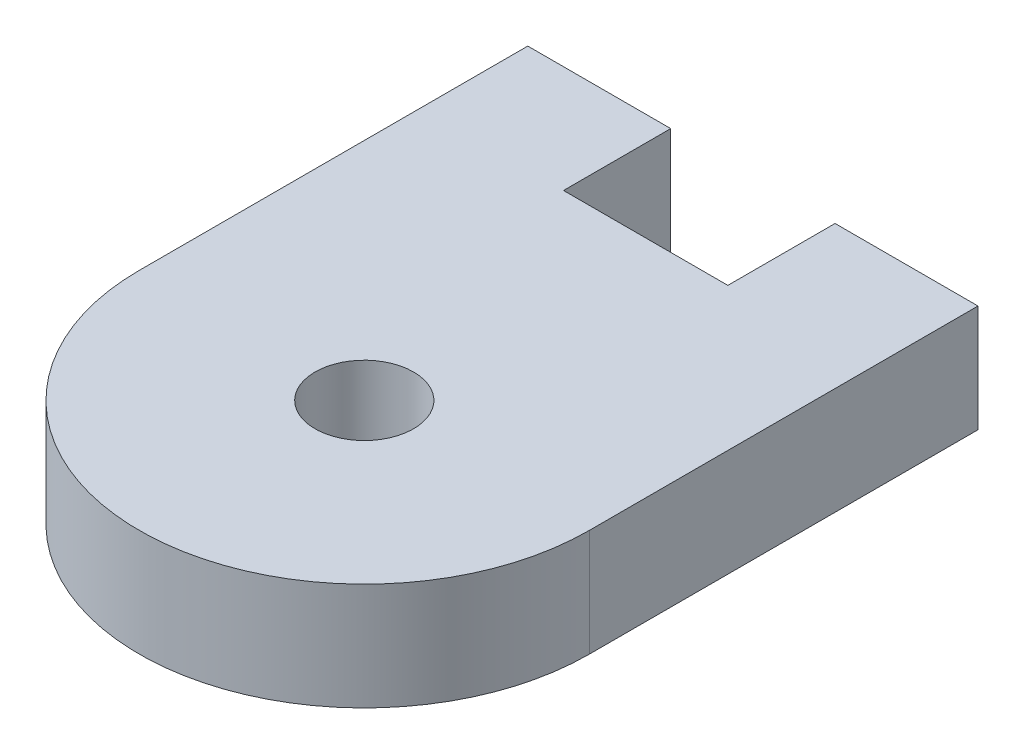
from build123d import *

# Parameters (mm, degrees)
BOSS_EXTRUDE1_DEPTH = 7.62
SKETCH2_R           = 3.5
CUT_EXTRUDE1_DEPTH  = 8.62
SKETCH3_W           = 10.16
SKETCH3_H           = 7.62
BOSS_EXTRUDE2_DEPTH = 7.62


with BuildPart() as part:
    # Sketch1 → Boss-Extrude1 (new body)
    with BuildSketch(Plane(origin=(0, 0, 0), x_dir=(1, 0, 0), z_dir=(0, 1, 0))):
        with BuildLine():
            Line((0, 0), (0, 20))
            Line((0, 20), (32, 20))
            Line((32, 20), (32, 0))
            ThreePointArc((32, 0), (16, -16), (0, 0))
        make_face()
    extrude(amount=BOSS_EXTRUDE1_DEPTH)

    # Sketch2 → Cut-Extrude1 (cut, through all)
    with BuildSketch(Plane.XZ):
        with Locations((16, 0)):
            Circle(SKETCH2_R)
    extrude(amount=-CUT_EXTRUDE1_DEPTH, mode=Mode.SUBTRACT)

    # Sketch3 → Boss-Extrude2 (add)
    with BuildSketch(Plane(origin=(0, 0, -20), x_dir=(-1, 0, 0), z_dir=(0, 0, -1))):
        with Locations((-26.92, 3.81)):
            Rectangle(SKETCH3_W, SKETCH3_H)
        with Locations((-5.08, 3.81)):
            Rectangle(SKETCH3_W, SKETCH3_H)
    extrude(amount=BOSS_EXTRUDE2_DEPTH)


solid = part.part
